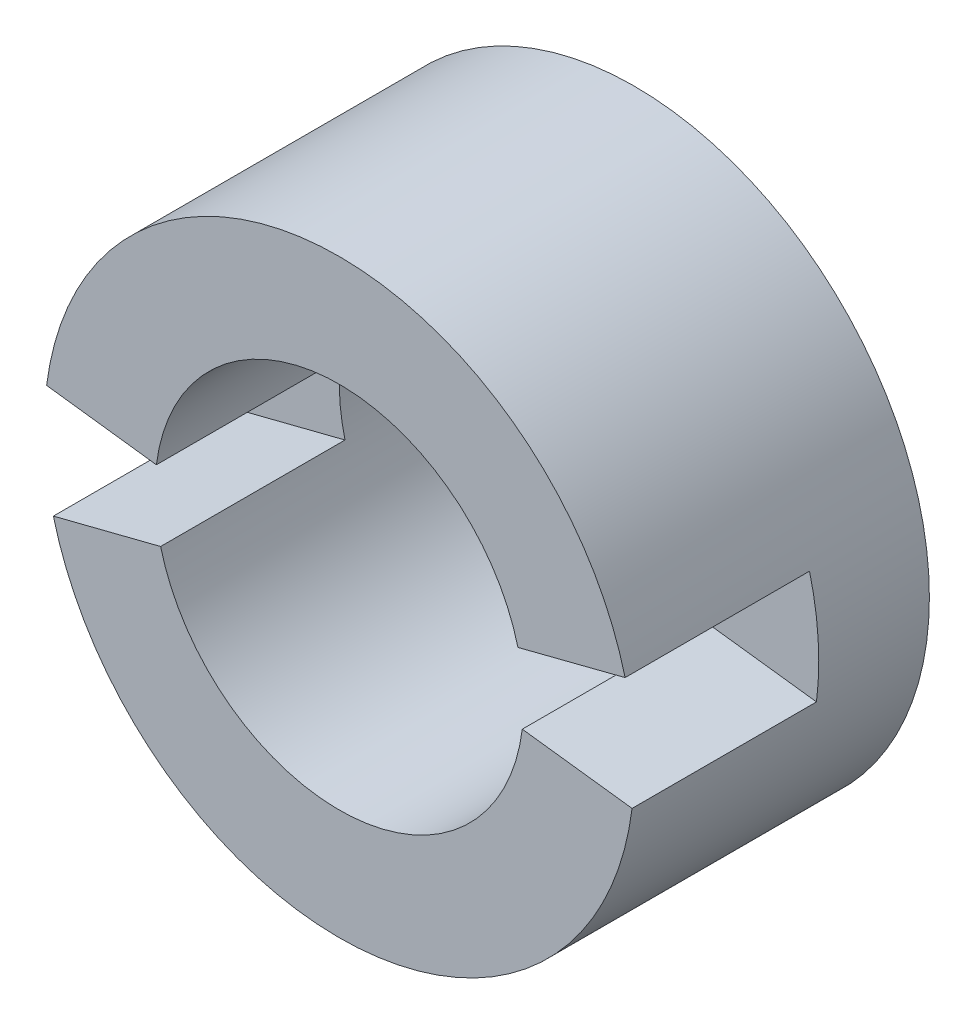
from build123d import *

# Parameters (mm, degrees)
SKETCH1_R                = 8
SKETCH1_R_2              = 5
BOSS_EXTRUDE1_DEPTH      = 8
WRAP2_SECTION_W          = 4
WRAP2_SECTION_H          = 5
WRAP2_ANGLE              = 21.485917317
WRAP2_SECTOR_2_SECTION_W = 4
WRAP2_SECTOR_2_SECTION_H = 5
WRAP2_SECTOR_2_ANGLE     = 21.485917317


with BuildPart() as part:
    # Sketch1 → Boss-Extrude1 (new body)
    with BuildSketch(Plane.XY):
        Circle(SKETCH1_R)
        Circle(SKETCH1_R_2, mode=Mode.SUBTRACT)
    extrude(amount=BOSS_EXTRUDE1_DEPTH)

    # Wrap2 section (on wrap section) → Wrap2 (revolve, cut)
    with BuildSketch(Plane(origin=(0, 0, 0), x_dir=(-0.9691091288804563, -0.24663230996883403, 0), z_dir=(0.24663230996883403, -0.9691091288804563, 0))):
        with Locations((6, -5.5)):
            Rectangle(WRAP2_SECTION_W, WRAP2_SECTION_H)
    revolve(axis=Axis((0, 0, 0), (0, 0, -1)), revolution_arc=WRAP2_ANGLE, mode=Mode.SUBTRACT)

    # Wrap2 sector 2 section (on wrap section) → Wrap2 sector 2 (revolve, cut)
    with BuildSketch(Plane(origin=(0, 0, 0), x_dir=(0.9687151001182653, 0.24817545165237268, 0), z_dir=(-0.24817545165237268, 0.9687151001182653, 0))):
        with Locations((6, -5.5)):
            Rectangle(WRAP2_SECTOR_2_SECTION_W, WRAP2_SECTOR_2_SECTION_H)
    revolve(axis=Axis((0, 0, 0), (0, 0, -1)), revolution_arc=WRAP2_SECTOR_2_ANGLE, mode=Mode.SUBTRACT)


solid = part.part
